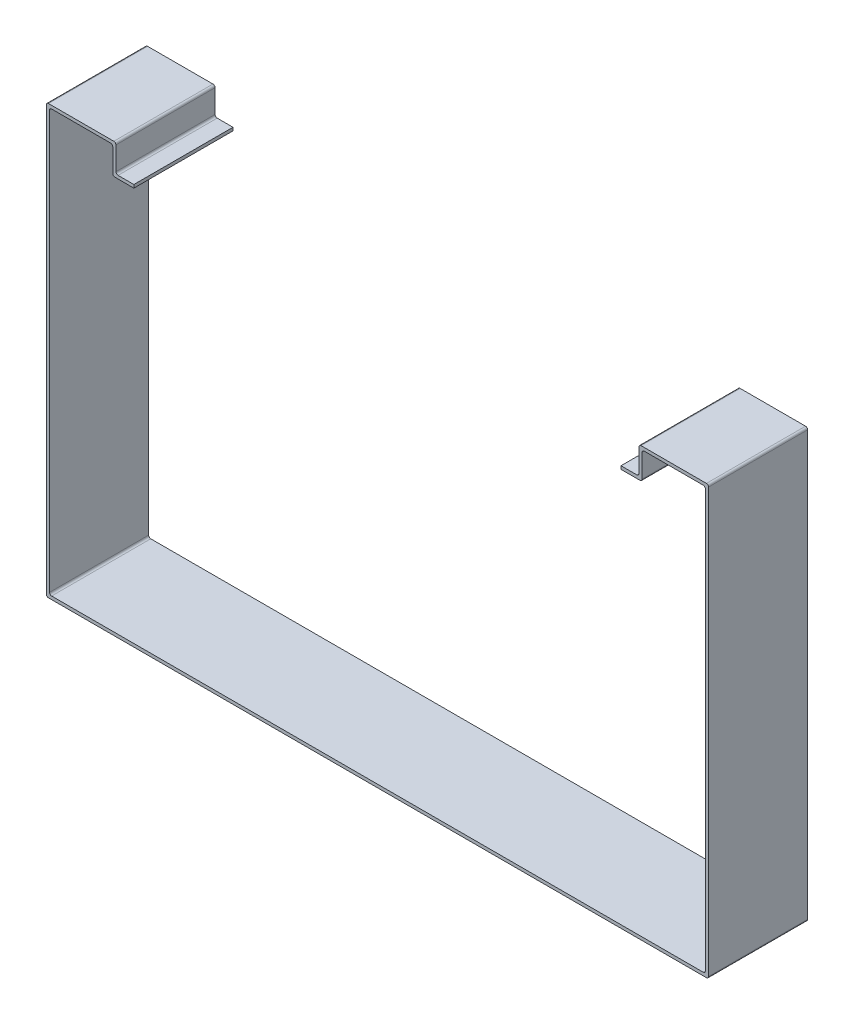
from build123d import *

# Parameters (mm, degrees)
EXTRUDE_1_DEPTH = 47


with BuildPart() as part:
    # 草图1 → 凸台-拉伸1 (new body)
    with BuildSketch(Plane.XY):
        with BuildLine():
            Line((18.639450369, 45.736574885), (46.639450369, 45.736574885))
            ThreePointArc((46.639450369, 45.736574885), (47.34655715, 45.443681666), (47.639450369, 44.736574885))
            Line((47.639450369, 44.736574885), (47.639450369, -153.263425115))
            ThreePointArc((47.639450369, -153.263425115), (47.34655715, -153.970531897), (46.639450369, -154.263425115))
            Line((46.639450369, -154.263425115), (-262.360549631, -154.263425115))
            ThreePointArc((-262.360549631, -154.263425115), (-263.067656412, -153.970531897), (-263.360549631, -153.263425115))
            Line((-263.360549631, -153.263425115), (-263.360549631, 44.736574885))
            ThreePointArc((-263.360549631, 44.736574885), (-263.067656412, 45.443681666), (-262.360549631, 45.736574885))
            Line((-262.360549631, 45.736574885), (-234.360549631, 45.736574885))
            ThreePointArc((-234.360549631, 45.736574885), (-233.65344285, 45.443681666), (-233.360549631, 44.736574885))
            Line((-233.360549631, 44.736574885), (-233.360549631, 33.736574885))
            ThreePointArc((-233.360549631, 33.736574885), (-233.067656412, 33.029468103), (-232.360549631, 32.736574885))
            Line((-232.360549631, 32.736574885), (-223.360549631, 32.736574885))
            Line((-223.360549631, 32.736574885), (-223.360549631, 34.236574885))
            Line((-223.360549631, 34.236574885), (-230.860549631, 34.236574885))
            ThreePointArc((-230.860549631, 34.236574885), (-231.567656412, 34.529468103), (-231.860549631, 35.236574885))
            Line((-231.860549631, 35.236574885), (-231.860549631, 46.236574885))
            ThreePointArc((-231.860549631, 46.236574885), (-232.15344285, 46.943681666), (-232.860549631, 47.236574885))
            Line((-232.860549631, 47.236574885), (-263.860549631, 47.236574885))
            ThreePointArc((-263.860549631, 47.236574885), (-264.567656412, 46.943681666), (-264.860549631, 46.236574885))
            Line((-264.860549631, 46.236574885), (-264.860549631, -154.763425115))
            ThreePointArc((-264.860549631, -154.763425115), (-264.567656412, -155.470531897), (-263.860549631, -155.763425115))
            Line((-263.860549631, -155.763425115), (48.139450369, -155.763425115))
            ThreePointArc((48.139450369, -155.763425115), (48.84655715, -155.470531897), (49.139450369, -154.763425115))
            Line((49.139450369, -154.763425115), (49.139450369, 46.236574885))
            ThreePointArc((49.139450369, 46.236574885), (48.84655715, 46.943681666), (48.139450369, 47.236574885))
            Line((48.139450369, 47.236574885), (17.139450369, 47.236574885))
            ThreePointArc((17.139450369, 47.236574885), (16.432343588, 46.943681666), (16.139450369, 46.236574885))
            Line((16.139450369, 46.236574885), (16.139450369, 35.236574885))
            ThreePointArc((16.139450369, 35.236574885), (15.84655715, 34.529468103), (15.139450369, 34.236574885))
            Line((15.139450369, 34.236574885), (7.639450369, 34.236574885))
            Line((7.639450369, 34.236574885), (7.639450369, 32.736574885))
            Line((7.639450369, 32.736574885), (16.639450369, 32.736574885))
            ThreePointArc((16.639450369, 32.736574885), (17.34655715, 33.029468103), (17.639450369, 33.736574885))
            Line((17.639450369, 33.736574885), (17.639450369, 44.736574885))
            ThreePointArc((17.639450369, 44.736574885), (17.932343588, 45.443681666), (18.639450369, 45.736574885))
        make_face()
    extrude(amount=EXTRUDE_1_DEPTH)


solid = part.part
